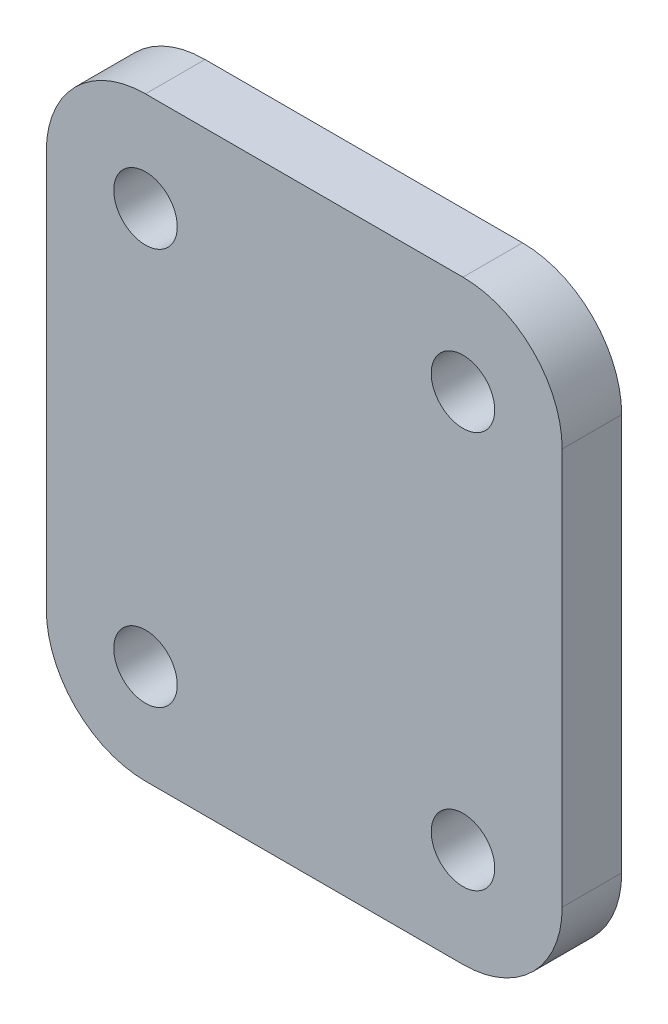
from build123d import *

# Parameters (mm, degrees)
ESBO_O1_W                = 26
ESBO_O1_H                = 30
ESBO_O1_R                = 1.6
RESSALTO_EXTRUS_O1_DEPTH = 3
FILETE1_R                = 5


with BuildPart() as part:
    # Esboço1 → Ressalto-extrusão1 (new body)
    with BuildSketch(Plane.XY):
        Rectangle(ESBO_O1_W, ESBO_O1_H)
        with Locations((-8, 10)):
            Circle(ESBO_O1_R, mode=Mode.SUBTRACT)
        with Locations((8, 10)):
            Circle(ESBO_O1_R, mode=Mode.SUBTRACT)
        with Locations((8, -10)):
            Circle(ESBO_O1_R, mode=Mode.SUBTRACT)
        with Locations((-8, -10)):
            Circle(ESBO_O1_R, mode=Mode.SUBTRACT)
    extrude(amount=RESSALTO_EXTRUS_O1_DEPTH)

    # Filete1
    filete1_edges = [part.edges().sort_by_distance(p)[0] for p in [
        (-13, -15, 1.5),
        (-13, 15, 1.5),
        (13, 15, 1.5),
        (13, -15, 1.5),
    ]]
    fillet(filete1_edges, radius=FILETE1_R)


solid = part.part
